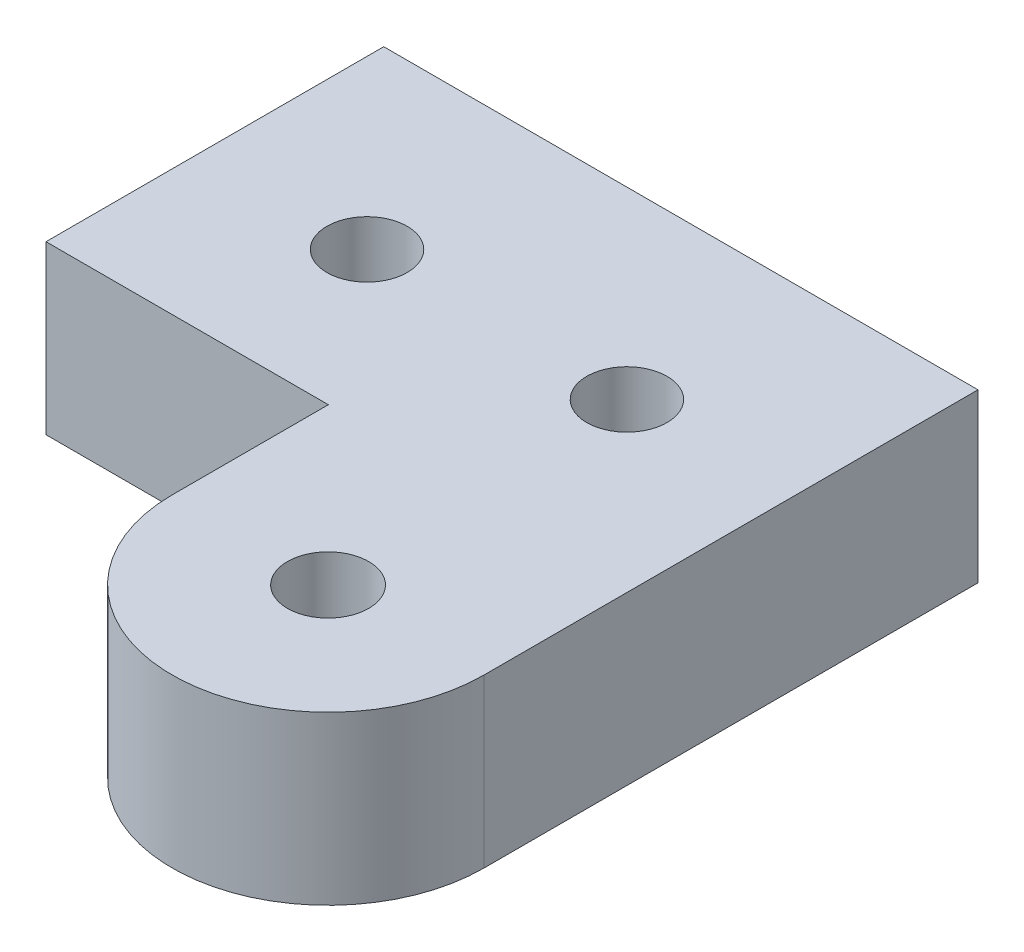
from build123d import *

# Parameters (mm, degrees)
BOSS_EXTRUDE1_DEPTH      = 5
M2_CLEARANCE_HOLE1_D     = 2.4
M2_CLEARANCE_HOLE1_DEPTH = 12
M2_CLEARANCE_HOLE1_TIP   = 0.721032743
SKETCH6_R                = 1.215
CUT_EXTRUDE1_DEPTH       = 10


with BuildPart() as part:
    # Sketch1 → Boss-Extrude1 (new body)
    with BuildSketch(Plane(origin=(0, 0, 0), x_dir=(1, 0, 0), z_dir=(0, 1, 0))):
        with BuildLine():
            Line((4.958856711, -28.278101888), (4.958856711, -16.278101888))
            Line((4.958856711, -16.278101888), (4.958856711, -13.505087823))
            Line((4.958856711, -13.505087823), (-12.812745649, -13.505087823))
            Line((-12.812745649, -13.505087823), (-12.812745649, -16.278101888))
            Line((-12.812745649, -16.278101888), (-12.812745649, -23.605635188))
            Line((-12.812745649, -23.605635188), (-4.368523326, -23.605635188))
            Line((-4.368523326, -23.605635188), (-4.368523326, -28.278101888))
            ThreePointArc((-4.368523326, -28.278101888), (0.295166692, -32.941791906), (4.958856711, -28.278101888))
        make_face()
    extrude(amount=BOSS_EXTRUDE1_DEPTH)

    # M2 Clearance Hole1
    with Locations(Plane(origin=(0, 5, 0), x_dir=(1, 0, 0), z_dir=(0, 1, 0))):
        with Locations((-0.041143289, -19.005087823), (-7.812745649, -19.005087823)):
            Hole(M2_CLEARANCE_HOLE1_D / 2, depth=M2_CLEARANCE_HOLE1_DEPTH)
            with Locations((0, 0, -(M2_CLEARANCE_HOLE1_DEPTH + M2_CLEARANCE_HOLE1_TIP / 2))):  # 118° drill point
                Cone(0, M2_CLEARANCE_HOLE1_D / 2, M2_CLEARANCE_HOLE1_TIP, mode=Mode.SUBTRACT)

    # Sketch6 → Cut-Extrude1 (cut)
    with BuildSketch(Plane(origin=(0, 5, 0), x_dir=(1, 0, 0), z_dir=(0, 1, 0))):
        with Locations((0.295166692, -28.278101888)):
            Circle(SKETCH6_R)
    extrude(amount=-CUT_EXTRUDE1_DEPTH, mode=Mode.SUBTRACT)


solid = part.part
